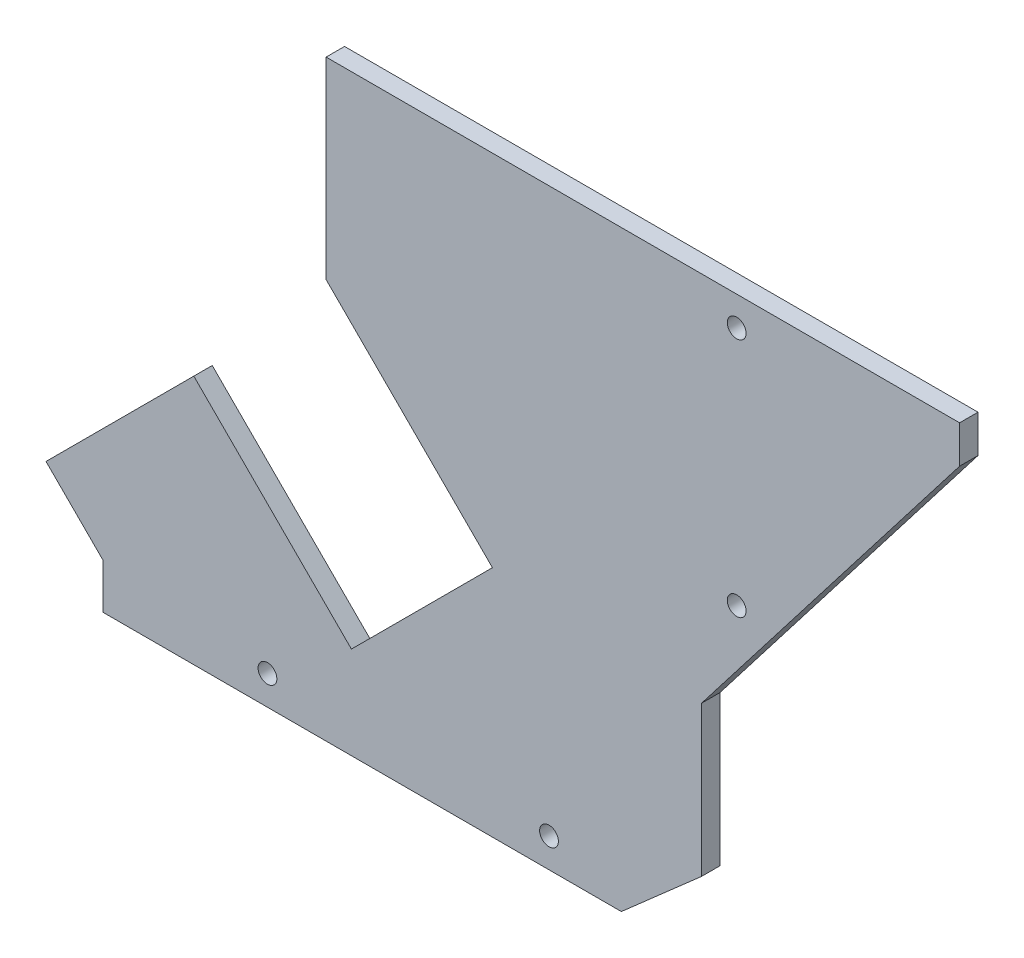
from build123d import *

# Parameters (mm, degrees)
BOSS_EXTRUDE1_DEPTH = 1.57
SKETCH4_R           = 0.8
CUT_EXTRUDE1_DEPTH  = 2.57


with BuildPart() as part:
    # Sketch2 → Boss-Extrude1 (new body)
    with BuildSketch(Plane.XY):
        Polygon((-14, -55.500103029), (-14, -51.671572877), (-18.878667627, -46.792905249), (-6.278214078, -34.1924517), (7.156814765, -47.627480542), (19.177630045, -35.606665262), (5, -21.429035217), (5, -5), (59, -5), (59, -8.204229809), (37.000000001, -36.704229808), (37.000000001, -49.491817554), (30.165562087, -55.500103029), align=None)
    extrude(amount=BOSS_EXTRUDE1_DEPTH)

    # Sketch4 → Cut-Extrude1 (cut, through all)
    with BuildSketch(Plane.XY.offset(1.57)):
        with Locations((39.999798764, -7.5)):
            Circle(SKETCH4_R)
        with Locations((39.999898107, -27.999885516)):
            Circle(SKETCH4_R)
        with Locations((24.000063681, -52.999991481)):
            Circle(SKETCH4_R)
        with Locations((6.3681e-05, -52.999991481)):
            Circle(SKETCH4_R)
    extrude(amount=-CUT_EXTRUDE1_DEPTH, mode=Mode.SUBTRACT)


solid = part.part
